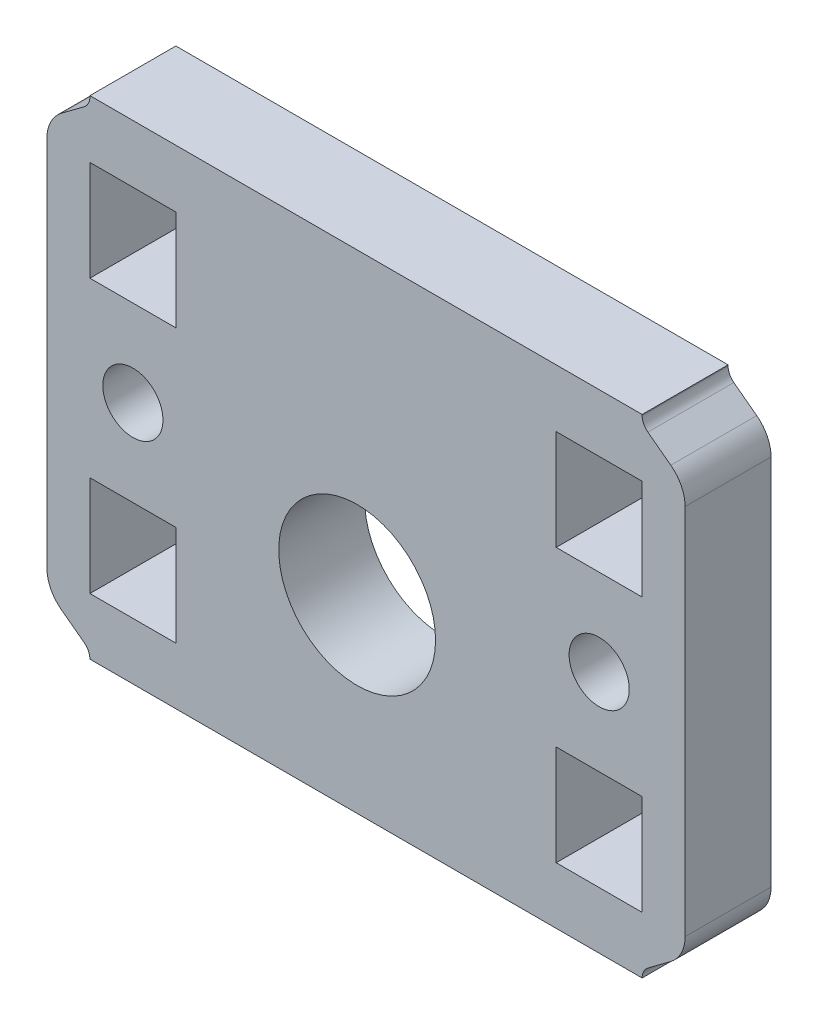
from build123d import *

# Parameters (mm, degrees)
SKETCH_1_W           = 38.55
SKETCH_1_H           = 34.06926437
EXTRUDE_1_DEPTH      = 6
SKETCH_2_R           = 5.475
CUT_EXTRUDE_1_DEPTH  = 7
EXTRUDE_2_DEPTH      = 6
SKETCH_3_R           = 2.1
SKETCH_3_W           = 7
SKETCH_3_H           = 6
CUT_EXTRUDE_13_DEPTH = 7
EXTRUDE_21_DEPTH     = 6
SKETCH_31_R          = 2.1
SKETCH_31_W          = 7
SKETCH_31_H          = 6
CUT_EXTRUDE_14_DEPTH = 7


with BuildPart() as part:
    # Эскиз1 → Бобышка-Вытянуть1 (new body)
    with BuildSketch(Plane.XY):
        with Locations((4.02043073, 23.206158468)):
            Rectangle(SKETCH_1_W, SKETCH_1_H)
    extrude(amount=EXTRUDE_1_DEPTH)

    # Эскиз2 → Вырез-Вытянуть1 (cut, through all)
    with BuildSketch(Plane.XY.offset(6)):
        with Locations((3.40043073, 19.378379342)):
            Circle(SKETCH_2_R)
    extrude(amount=-CUT_EXTRUDE_1_DEPTH, mode=Mode.SUBTRACT)

    # Эскиз23 → Бобышка-Вытянуть2 (add)
    with BuildSketch(Plane(origin=(-26.70456927, 23.171526283, 6), x_dir=(0, 1, 0), z_dir=(0, 0, -1))):
        with BuildLine():
            Line((13, 53), (-13, 53))
            ThreePointArc((-13, 53), (-14.118033989, 52.736067977), (-15, 52))
            Line((-15, 52), (-16.2, 50.4))
            ThreePointArc((-16.2, 50.4), (-16.552786405, 50.105572809), (-17, 50))
            Line((-17, 50), (17, 50))
            ThreePointArc((17, 50), (16.552786405, 50.105572809), (16.2, 50.4))
            Line((16.2, 50.4), (15, 52))
            ThreePointArc((15, 52), (14.118033989, 52.736067977), (13, 53))
        make_face()
    extrude(amount=EXTRUDE_2_DEPTH)

    # Эскиз3 → Вырез-Вытянуть13 (cut, through all)
    with BuildSketch(Plane(origin=(-26.70456927, 23.171526283, 0), x_dir=(0, 1, 0), z_dir=(0, 0, -1))):
        with Locations((0, 47)):
            Circle(SKETCH_3_R)
        with Locations((9.531849908, 47)):
            Rectangle(SKETCH_3_W, SKETCH_3_H)
        with Locations((-9.531849908, 47)):
            Rectangle(SKETCH_3_W, SKETCH_3_H)
    extrude(amount=-CUT_EXTRUDE_13_DEPTH, mode=Mode.SUBTRACT)

    # Эскиз24 → Бобышка-Вытянуть21 (add)
    with BuildSketch(Plane(origin=(34.74543073, 23.171526283, 6), x_dir=(0, -1, 0), z_dir=(0, 0, -1))):
        with BuildLine():
            Line((13, 53), (-13, 53))
            ThreePointArc((-13, 53), (-14.118033989, 52.736067977), (-15, 52))
            Line((-15, 52), (-16.2, 50.4))
            ThreePointArc((-16.2, 50.4), (-16.552786405, 50.105572809), (-17, 50))
            Line((-17, 50), (17, 50))
            ThreePointArc((17, 50), (16.552786405, 50.105572809), (16.2, 50.4))
            Line((16.2, 50.4), (15, 52))
            ThreePointArc((15, 52), (14.118033989, 52.736067977), (13, 53))
        make_face()
    extrude(amount=EXTRUDE_21_DEPTH)

    # Эскиз31 → Вырез-Вытянуть14 (cut, through all)
    with BuildSketch(Plane(origin=(34.74543073, 23.171526283, 0), x_dir=(0, -1, 0), z_dir=(0, 0, -1))):
        with Locations((0, 47)):
            Circle(SKETCH_31_R)
        with Locations((9.531849908, 47)):
            Rectangle(SKETCH_31_W, SKETCH_31_H)
        with Locations((-9.531849908, 47)):
            Rectangle(SKETCH_31_W, SKETCH_31_H)
    extrude(amount=-CUT_EXTRUDE_14_DEPTH, mode=Mode.SUBTRACT)


solid = part.part
